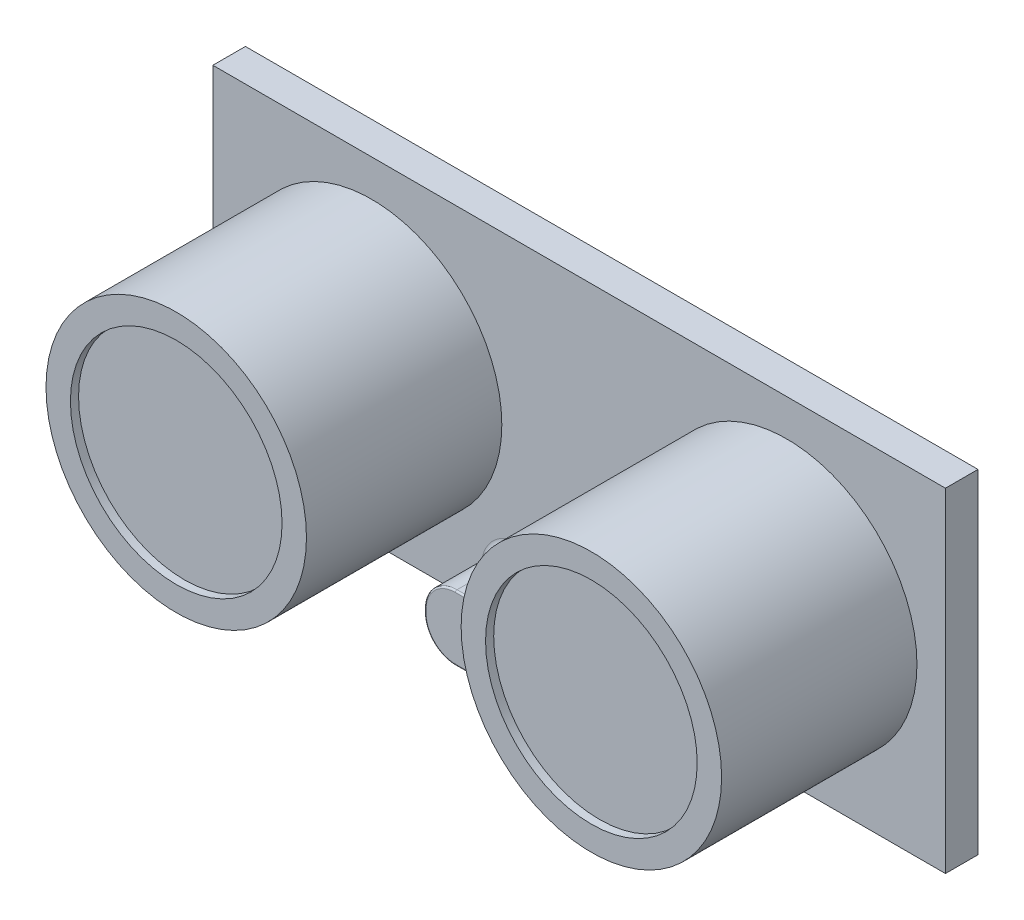
from build123d import *

# Parameters (mm, degrees)
BOSS_EXTRUDE1_DEPTH = 2
SKETCH2_R           = 7.999999999999998
BOSS_EXTRUDE2_DEPTH = 12
SKETCH3_R           = 6.499999999999999
SKETCH3_R_2         = 6.5
CUT_EXTRUDE1_DEPTH  = 0.5
BOSS_EXTRUDE3_DEPTH = 4
FILLET1_R           = 0.1
FILLET2_R           = 0.5


with BuildPart() as part:
    # Sketch1 → Boss-Extrude1 (new body)
    with BuildSketch(Plane.XY):
        Polygon((22.499999999999993, -10.249999999999996), (-22.500000000000007, -10.25), (-22.500000000000007, 10.25), (22.499999999999993, 10.250000000000005), align=None)
    extrude(amount=BOSS_EXTRUDE1_DEPTH)

    # Sketch2 → Boss-Extrude2 (add)
    with BuildSketch(Plane.XY.offset(2)):
        with Locations((-12.750000000000004, 1.12e-15)):
            Circle(SKETCH2_R)
        with Locations((12.749999999999998, 1.12e-15)):
            Circle(SKETCH2_R)
    extrude(amount=BOSS_EXTRUDE2_DEPTH)

    # Sketch3 → Cut-Extrude1 (cut)
    with BuildSketch(Plane.XY.offset(14)):
        with Locations((-12.750000000000004, 1.12e-15)):
            Circle(SKETCH3_R)
        with Locations(Location((12.749999999999991, -2.316e-14, 0), (0, 0, 180))):
            Circle(SKETCH3_R_2)
    extrude(amount=-CUT_EXTRUDE1_DEPTH, mode=Mode.SUBTRACT)

    # Sketch4 → Boss-Extrude3 (add)
    with BuildSketch(Plane.XY.offset(2)):
        with BuildLine():
            Line((3.5999999999999757, -10.249999999999995), (-3.5999999999999965, -10.249999999999996))
            ThreePointArc((-3.5999999999999965, -10.249999999999996), (-4.943502884254451, -9.693502884254437), (-5.50000000000001, -8.349999999999982))
            Line((-5.50000000000001, -8.349999999999982), (-5.50000000000001, -8.15000000000001))
            ThreePointArc((-5.50000000000001, -8.15000000000001), (-4.943502884254451, -6.8064971157455565), (-3.5999999999999965, -6.2499999999999964))
            Line((-3.5999999999999965, -6.2499999999999964), (3.5999999999999757, -6.249999999999996))
            ThreePointArc((3.5999999999999757, -6.249999999999996), (4.943502884254429, -6.806497115745555), (5.499999999999989, -8.150000000000007))
            Line((5.499999999999989, -8.150000000000007), (5.499999999999989, -8.349999999999982))
            ThreePointArc((5.499999999999989, -8.349999999999982), (4.943502884254429, -9.693502884254436), (3.5999999999999757, -10.249999999999995))
        make_face()
    extrude(amount=BOSS_EXTRUDE3_DEPTH)

    # Fillet1
    fillet1_edges = [part.edges().sort_by_distance(p)[0] for p in [
        (4.94350288425443, -9.693502884254436, 6),
        (5.499999999999989, -8.249999999999995, 6),
        (4.943502884254428, -6.806497115745555, 6),
        (-1.021e-14, -6.2499999999999964, 6),
        (-4.94350288425445, -6.8064971157455565, 6),
        (-5.50000000000001, -8.249999999999996, 6),
        (-4.943502884254451, -9.693502884254437, 6),
        (-1.066e-14, -10.249999999999996, 6),
    ]]
    fillet(fillet1_edges, radius=FILLET1_R)

    # Fillet2
    fillet2_edges = [part.edges().sort_by_distance(p)[0] for p in [
        (4.94350288425443, -9.693502884254436, 2),
        (5.499999999999989, -8.249999999999995, 2),
        (4.943502884254428, -6.806497115745555, 2),
        (-1.021e-14, -6.2499999999999964, 2),
        (-4.94350288425445, -6.8064971157455565, 2),
        (-5.50000000000001, -8.249999999999996, 2),
        (-4.943502884254451, -9.693502884254437, 2),
    ]]
    fillet(fillet2_edges, radius=FILLET2_R)


solid = part.part
